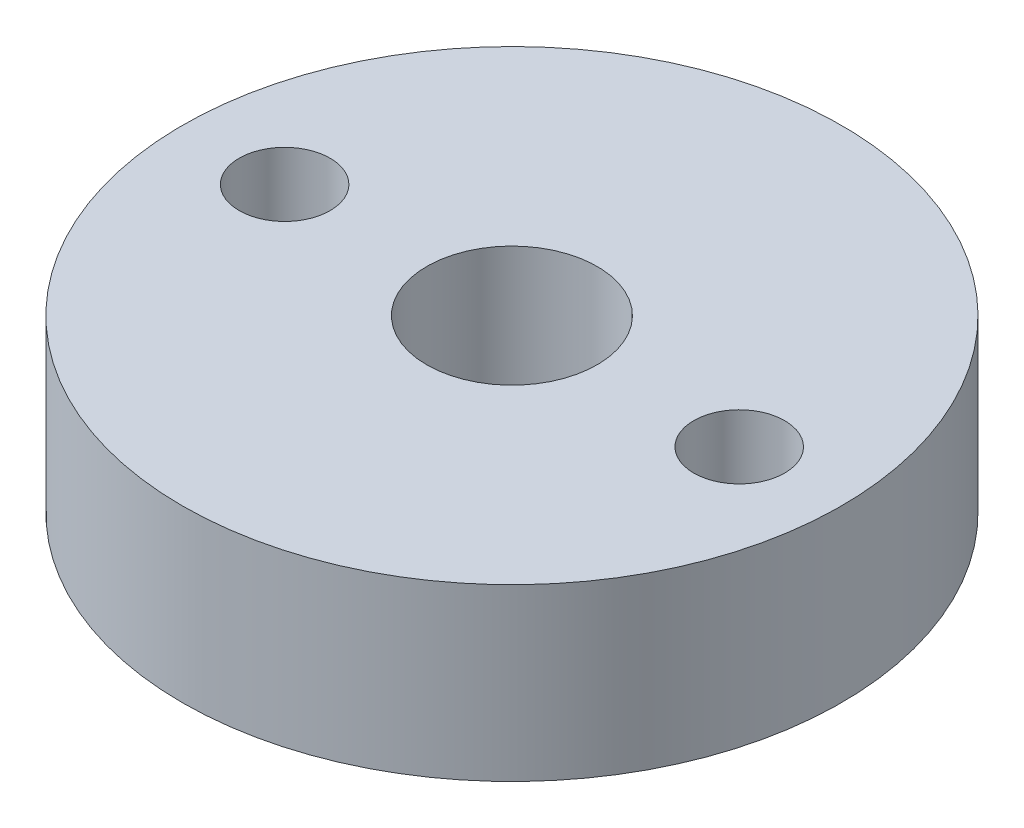
from build123d import *

# Parameters (mm, degrees)
ESBO_O1_R                = 11.6
ESBO_O1_R_2              = 1.6
ESBO_O1_R_3              = 3
RESSALTO_EXTRUS_O1_DEPTH = 6


with BuildPart() as part:
    # Esboço1 → Ressalto-extrusão1 (new body)
    with BuildSketch(Plane.XZ.offset(6)):
        Circle(ESBO_O1_R)
        with Locations((8, 0)):
            Circle(ESBO_O1_R_2, mode=Mode.SUBTRACT)
        Circle(ESBO_O1_R_3, mode=Mode.SUBTRACT)
        with Locations((-8, 0)):
            Circle(ESBO_O1_R_2, mode=Mode.SUBTRACT)
    extrude(amount=-RESSALTO_EXTRUS_O1_DEPTH)


solid = part.part
